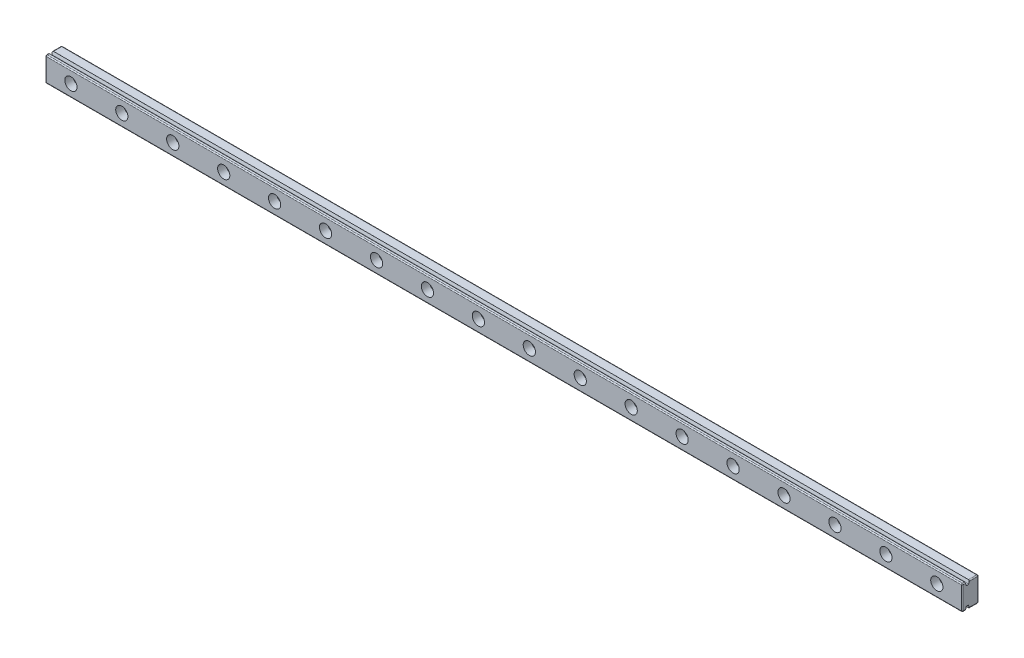
from build123d import *

# Parameters (mm, degrees)
BOSS_EXTRUDE1_DEPTH   = 450
SKETCH2_R             = 1.75
CUT_EXTRUDE1_DEPTH    = 10
SKETCH3_R             = 3
CUT_EXTRUDE2_DEPTH    = 4
CHAMFER1_SIZE         = 0.5
CHAMFER1_SIZE2        = 1.743707222
CHAMFER1_PART_2_SIZE  = 0.5
CHAMFER1_PART_2_SIZE2 = 1.743707222
FILLET1_R             = 0.5


with BuildPart() as part:
    # Sketch1 → Boss-Extrude1 (new body)
    with BuildSketch(Plane(origin=(0, 0, 0), x_dir=(0, 0, -1), z_dir=(1, 0, 0))):
        Polygon((-0.5, 6), (4, 6), (4, -6), (-0.5, -6), (-0.5, -4.25), (-2.5, -4.25), (-2.5, -6), (-4, -6), (-4, 6), (-2.5, 6), (-2.5, 4.25), (-0.5, 4.25), align=None)
    extrude(amount=BOSS_EXTRUDE1_DEPTH)

    # Sketch2 → Cut-Extrude1 (cut)
    with BuildSketch(Plane.XY.offset(4)):
        with Locations((12.5, 0)):
            Circle(SKETCH2_R)
        with Locations((37.5, 0)):
            Circle(SKETCH2_R)
        with Locations((62.5, 0)):
            Circle(SKETCH2_R)
        with Locations((87.5, 0)):
            Circle(SKETCH2_R)
        with Locations((112.5, 0)):
            Circle(SKETCH2_R)
        with Locations((137.5, 0)):
            Circle(SKETCH2_R)
        with Locations((162.5, 0)):
            Circle(SKETCH2_R)
        with Locations((187.5, 0)):
            Circle(SKETCH2_R)
        with Locations((212.5, 0)):
            Circle(SKETCH2_R)
        with Locations((237.5, 0)):
            Circle(SKETCH2_R)
        with Locations((262.5, 0)):
            Circle(SKETCH2_R)
        with Locations((287.5, 0)):
            Circle(SKETCH2_R)
        with Locations((312.5, 0)):
            Circle(SKETCH2_R)
        with Locations((337.5, 0)):
            Circle(SKETCH2_R)
        with Locations((362.5, 0)):
            Circle(SKETCH2_R)
        with Locations((387.5, 0)):
            Circle(SKETCH2_R)
        with Locations((412.5, 0)):
            Circle(SKETCH2_R)
        with Locations((437.5, 0)):
            Circle(SKETCH2_R)
    extrude(amount=-CUT_EXTRUDE1_DEPTH, mode=Mode.SUBTRACT)

    # Sketch3 → Cut-Extrude2 (cut)
    with BuildSketch(Plane.XY.offset(4)):
        with Locations((12.5, 0)):
            Circle(SKETCH3_R)
        with Locations((37.5, 0)):
            Circle(SKETCH3_R)
        with Locations((62.5, 0)):
            Circle(SKETCH3_R)
        with Locations((87.5, 0)):
            Circle(SKETCH3_R)
        with Locations((112.5, 0)):
            Circle(SKETCH3_R)
        with Locations((137.5, 0)):
            Circle(SKETCH3_R)
        with Locations((162.5, 0)):
            Circle(SKETCH3_R)
        with Locations((187.5, 0)):
            Circle(SKETCH3_R)
        with Locations((212.5, 0)):
            Circle(SKETCH3_R)
        with Locations((237.5, 0)):
            Circle(SKETCH3_R)
        with Locations((262.5, 0)):
            Circle(SKETCH3_R)
        with Locations((287.5, 0)):
            Circle(SKETCH3_R)
        with Locations((312.5, 0)):
            Circle(SKETCH3_R)
        with Locations((337.5, 0)):
            Circle(SKETCH3_R)
        with Locations((362.5, 0)):
            Circle(SKETCH3_R)
        with Locations((387.5, 0)):
            Circle(SKETCH3_R)
        with Locations((412.5, 0)):
            Circle(SKETCH3_R)
        with Locations((437.5, 0)):
            Circle(SKETCH3_R)
    extrude(amount=-CUT_EXTRUDE2_DEPTH, mode=Mode.SUBTRACT)

    # Chamfer1
    chamfer1_edges = [part.edges().sort_by_distance(p)[0] for p in [
        (225, -4.25, 0.5),
        (225, -4.25, 2.5),
    ]]
    chamfer1_side = [part.faces().sort_by_distance(p)[0] for p in [
        (225, -4.25, 1.5),
    ]]
    chamfer(chamfer1_edges, length=CHAMFER1_SIZE, length2=CHAMFER1_SIZE2, reference=chamfer1_side[0])

    # Chamfer1 part 2
    chamfer1_part_2_edges = [part.edges().sort_by_distance(p)[0] for p in [
        (225, 4.25, 2.5),
        (225, 4.25, 0.5),
    ]]
    chamfer1_part_2_side = [part.faces().sort_by_distance(p)[0] for p in [
        (225, 4.25, 1.5),
    ]]
    chamfer(chamfer1_part_2_edges, length=CHAMFER1_PART_2_SIZE, length2=CHAMFER1_PART_2_SIZE2, reference=chamfer1_part_2_side[0])

    # Fillet1
    fillet1_edges = [part.edges().sort_by_distance(p)[0] for p in [
        (450, -6, -1.75),
        (450, 0, -4),
        (450, 6, -1.75),
        (450, 6, 3.25),
        (450, 0, 4),
        (450, -6, 3.25),
        (0, -6, 3.25),
        (0, -6, -1.75),
        (0, 0, -4),
        (0, 6, -1.75),
        (0, 6, 3.25),
        (0, 0, 4),
        (225, -4.25, 1),
        (225, -4.25, 2),
        (225, 4.25, 2),
        (225, 4.25, 1),
        (225, -6, 4),
        (225, 6, 4),
        (225, -6, -4),
        (225, 6, -4),
    ]]
    fillet(fillet1_edges, radius=FILLET1_R)


solid = part.part
